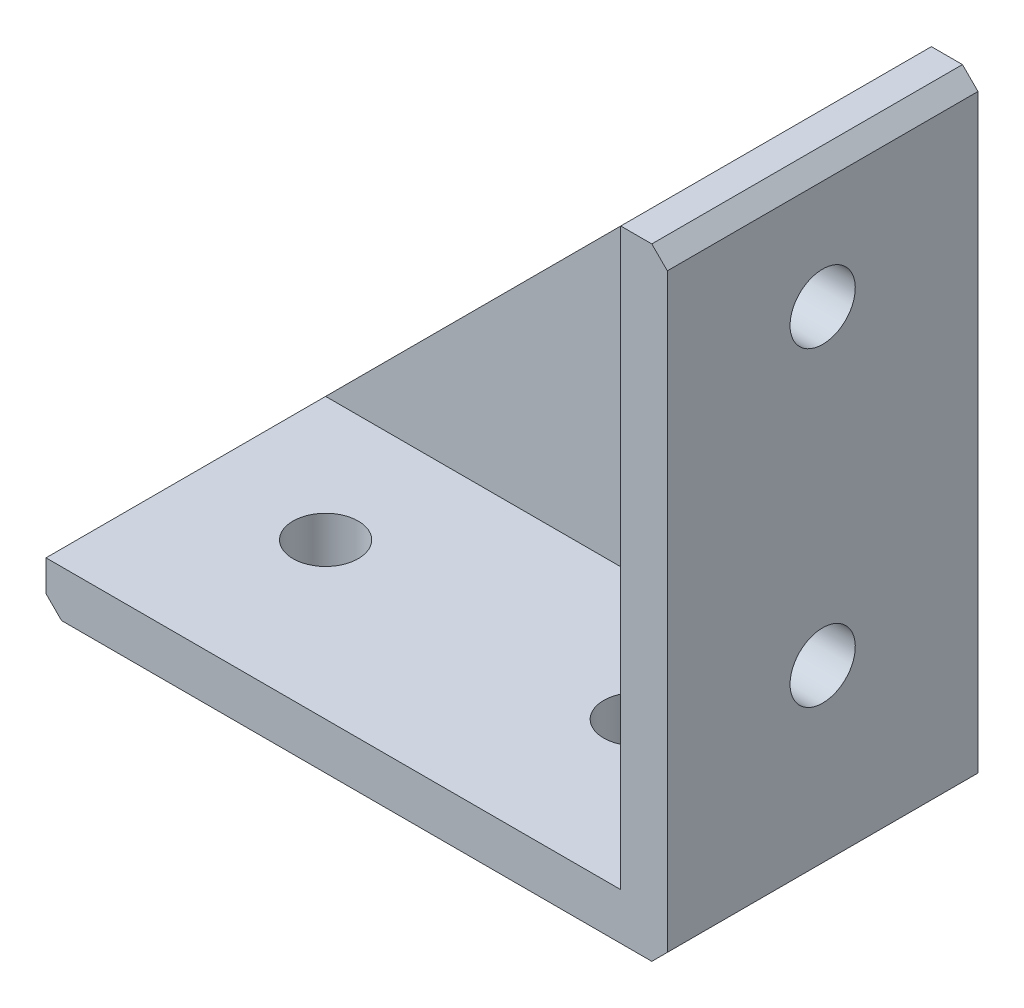
from build123d import *

# Parameters (mm, degrees)
ESQUISSE1_W             = 40
ESQUISSE1_H             = 40
BOSS_EXTRU_1_DEPTH      = 20
ESQUISSE2_W             = 37
ESQUISSE2_H             = 37
ENL_V_MAT_EXTRU_1_DEPTH = 18
ENL_V_MAT_EXTRU_2_DEPTH = 3
CHANFREIN1_SIZE         = 1
ESQUISSE4_R             = 2.1
ENL_V_MAT_EXTRU_3_DEPTH = 4
ESQUISSE5_R             = 2.1
ENL_V_MAT_EXTRU_4_DEPTH = 4


with BuildPart() as part:
    # Esquisse1 → Boss.-Extru.1 (new body)
    with BuildSketch(Plane.XY):
        with Locations((-20, 20)):
            Rectangle(ESQUISSE1_W, ESQUISSE1_H)
    extrude(amount=BOSS_EXTRU_1_DEPTH)

    # Esquisse2 → Enlèv. mat.-Extru.1 (cut)
    with BuildSketch(Plane.XY.offset(20)):
        with Locations((-21.5, 21.5)):
            Rectangle(ESQUISSE2_W, ESQUISSE2_H)
    extrude(amount=-ENL_V_MAT_EXTRU_1_DEPTH, mode=Mode.SUBTRACT)

    # Esquisse3 → Enlèv. mat.-Extru.2 (cut, through all)
    with BuildSketch(Plane.XY.offset(2)):
        Polygon((-40, 3), (-3, 40), (-40, 40), align=None)
    extrude(amount=-ENL_V_MAT_EXTRU_2_DEPTH, mode=Mode.SUBTRACT)

    # Chanfrein1
    chanfrein1_edges = [part.edges().sort_by_distance(p)[0] for p in [
        (0, 0, 10),
        (-40, 0, 10),
        (0, 40, 10),
    ]]
    chamfer(chanfrein1_edges, length=CHANFREIN1_SIZE)

    # Esquisse4 → Enlèv. mat.-Extru.3 (cut, through all)
    with BuildSketch(Plane(origin=(0, 3, 0), x_dir=(1, 0, 0), z_dir=(0, 1, 0))):
        with Locations((-12, -10)):
            Circle(ESQUISSE4_R)
        with Locations((-32, -10)):
            Circle(ESQUISSE4_R)
    extrude(amount=-ENL_V_MAT_EXTRU_3_DEPTH, mode=Mode.SUBTRACT)

    # Esquisse5 → Enlèv. mat.-Extru.4 (cut, through all)
    with BuildSketch(Plane.ZY.offset(3)):
        with Locations((10, 12)):
            Circle(ESQUISSE5_R)
        with Locations((10, 32)):
            Circle(ESQUISSE5_R)
    extrude(amount=-ENL_V_MAT_EXTRU_4_DEPTH, mode=Mode.SUBTRACT)


solid = part.part
